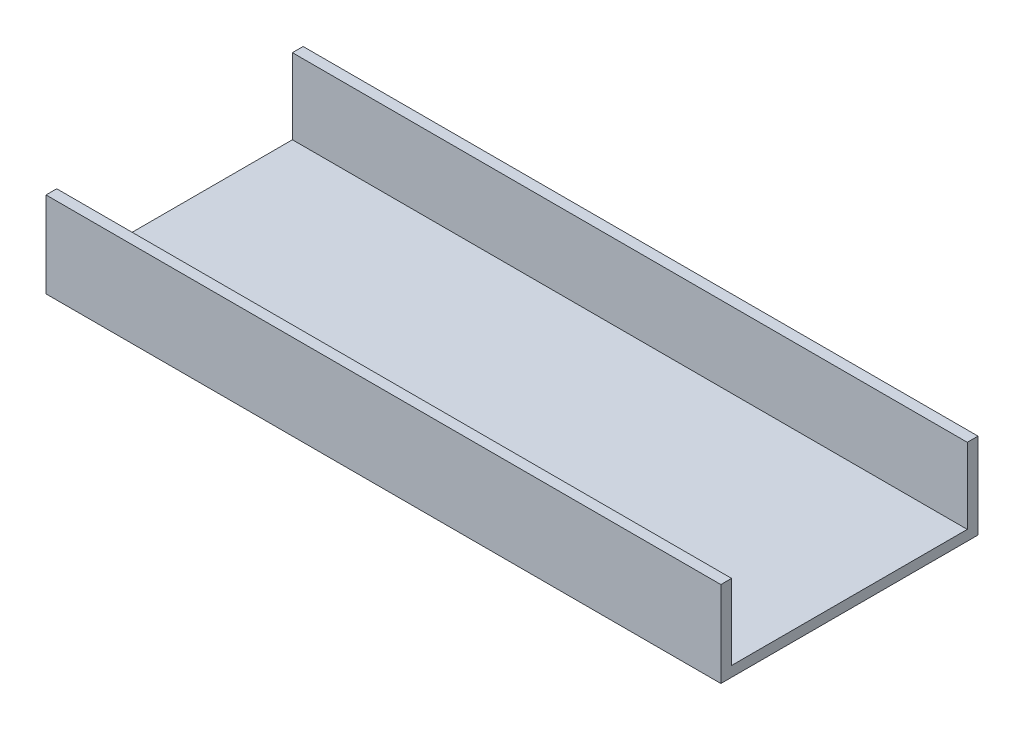
from build123d import *

# Parameters (mm, degrees)
BOSS_EXTRUDE1_DEPTH = 200


with BuildPart() as part:
    # Sketch1 → Boss-Extrude1 (new body)
    with BuildSketch(Plane(origin=(0, 0, 0), x_dir=(0, 0, -1), z_dir=(1, 0, 0))):
        Polygon((48.748079985, 22.352), (48.748079985, 0), (-21.101920015, 0), (-21.101920015, 22.352), (-24.276920015, 22.352), (-24.276920015, -3.048), (51.923079985, -3.048), (51.923079985, 22.352), align=None)
    extrude(amount=BOSS_EXTRUDE1_DEPTH)


solid = part.part
